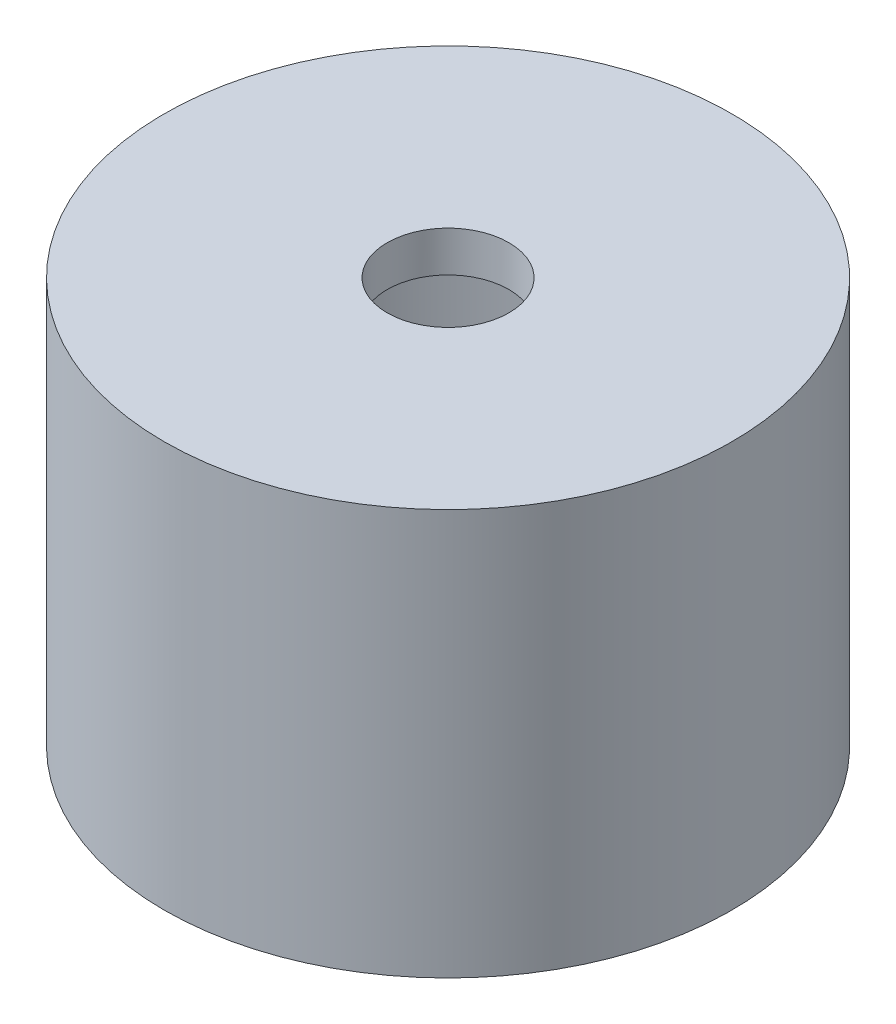
from build123d import *

# Parameters (mm, degrees)
SKETCH1_R           = 7
BOSS_EXTRUDE1_DEPTH = 10
SHELL1_T            = -1
SKETCH2_R           = 1.5
CUT_EXTRUDE1_DEPTH  = 10


with BuildPart() as part:
    # Sketch1 → Boss-Extrude1 (new body)
    with BuildSketch(Plane(origin=(0, 0, 0), x_dir=(1, 0, 0), z_dir=(0, 1, 0))):
        with Locations(Location((0, 0, 0), (0, 0, 270))):
            Circle(SKETCH1_R)
    extrude(amount=BOSS_EXTRUDE1_DEPTH)

    # Shell1
    shell1_openings = [part.faces().sort_by_distance(p)[0] for p in [
        (0, 0, 0),
    ]]
    offset(amount=SHELL1_T, openings=shell1_openings, kind=Kind.INTERSECTION)

    # Sketch2 → Cut-Extrude1 (cut)
    with BuildSketch(Plane(origin=(0, 9, 0), x_dir=(-1, 0, 0), z_dir=(0, -1, 0))):
        with Locations(Location((0, 0, 0), (0, 0, 90))):
            Circle(SKETCH2_R)
    extrude(amount=-CUT_EXTRUDE1_DEPTH, mode=Mode.SUBTRACT)


solid = part.part
